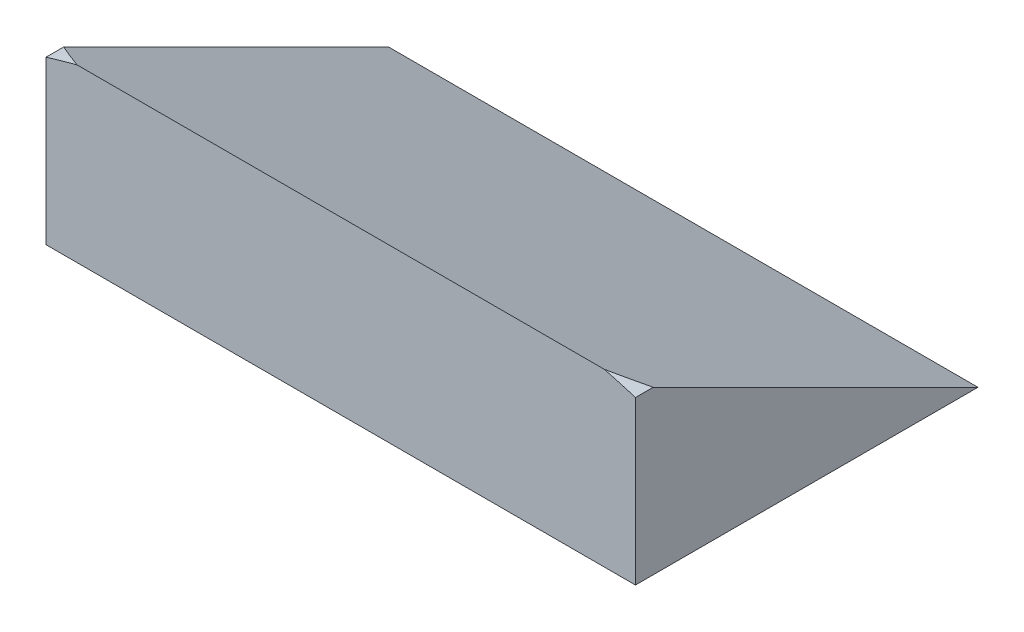
from build123d import *

# Parameters (mm, degrees)
BOSS_EXTRUDE2_DEPTH      = 200
CUT_EXTRUDE10_DEPTH      = 138.5000001
CUT_EXTRUDE10_DEPTH_BACK = 138.5000001


with BuildPart() as part:
    # Sketch18 → Boss-Extrude2 (new body)
    with BuildSketch(Plane.XY):
        with BuildLine():
            Line((137.5, 90.870921856), (137.5, 15.1))
            Line((137.5, 15.1), (-137.5, 15.1))
            Line((-137.5, 15.1), (-137.5, 90.870921856))
            add(Edge.make_bspline(
                [(137.5, 90.870921856), (0, 133.155906783), (-137.5, 90.870921856)],
                knots=[4.113742813, 4.113742813, 4.113742813, 5.311035148, 5.311035148, 5.311035148], degree=2, weights=[1, 0.82609929, 1]))
        make_face()
    extrude(amount=-BOSS_EXTRUDE2_DEPTH)

    # Sketch15 → Cut-Extrude10 (cut, two sides)
    with BuildSketch(Plane(origin=(0, 0, 0), x_dir=(0, 0, -1), z_dir=(1, 0, 0))) as cut_extrude10_sk:
        Polygon((0, 110), (0, 95), (200, -5), (200, 110), align=None)
    extrude(amount=CUT_EXTRUDE10_DEPTH, mode=Mode.SUBTRACT)
    extrude(cut_extrude10_sk.sketch, amount=-CUT_EXTRUDE10_DEPTH_BACK, mode=Mode.SUBTRACT)


solid = part.part
